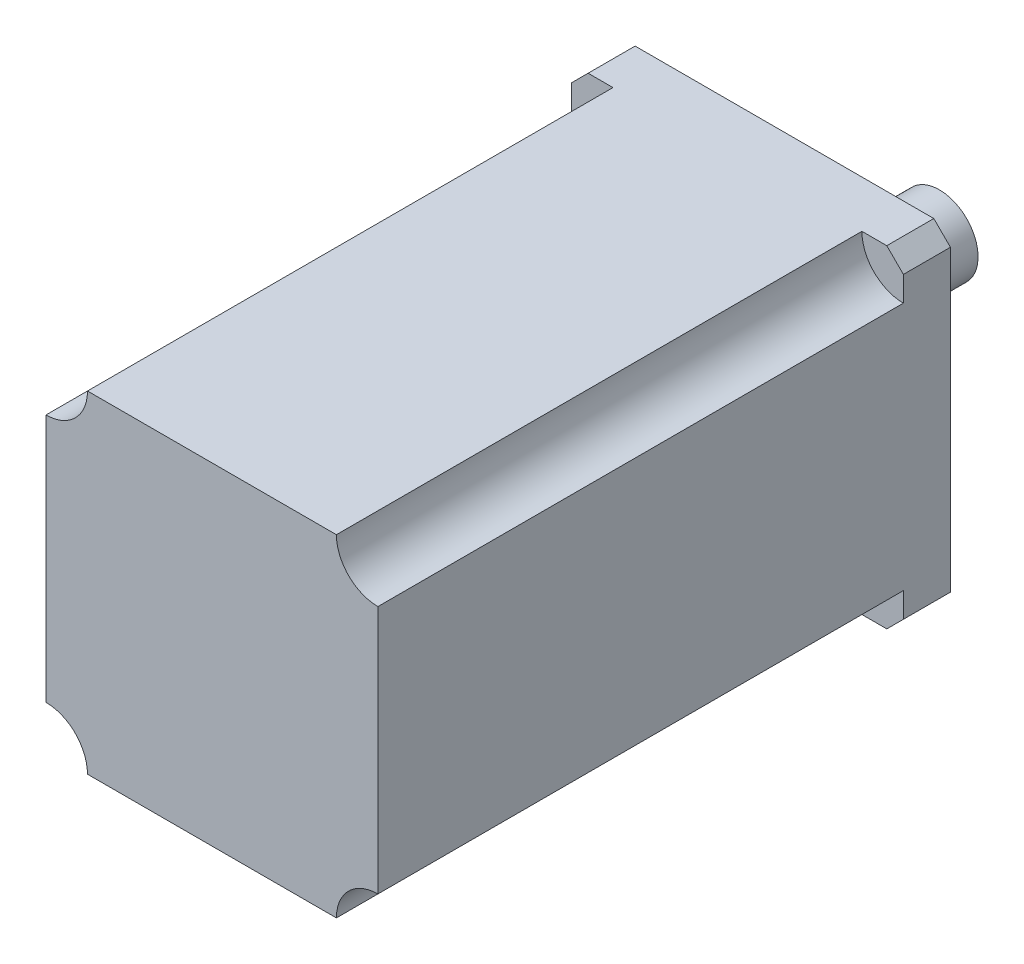
from build123d import *

# Parameters (mm, degrees)
EXTRUDE_1_DEPTH = 95
SKETCH_3_W      = 60
SKETCH_3_H      = 60
EXTRUDE_3_DEPTH = 8.5
SKETCH_5_R      = 25
EXTRUDE_5_DEPTH = 3
SKETCH_7_R      = 7
EXTRUDE_6_DEPTH = 25
CHAMFER_1_SIZE  = 3


with BuildPart() as part:
    # 草图1 → 凸台-拉伸1 (new body)
    with BuildSketch(Plane.XY):
        with BuildLine():
            Line((7.5, 0), (52.5, 0))
            ThreePointArc((52.5, 0), (54.696699141, -5.303300859), (60, -7.5))
            Line((60, -7.5), (60, -52.5))
            ThreePointArc((60, -52.5), (54.696699141, -54.696699141), (52.5, -60))
            Line((52.5, -60), (7.5, -60))
            ThreePointArc((7.5, -60), (5.303300859, -54.696699141), (0, -52.5))
            Line((0, -52.5), (0, -7.5))
            ThreePointArc((0, -7.5), (5.303300859, -5.303300859), (7.5, 0))
        make_face()
    extrude(amount=EXTRUDE_1_DEPTH)

    # 草图3 → 凸台-拉伸3 (add)
    with BuildSketch(Plane(origin=(0, 0, 0), x_dir=(-1, 0, 0), z_dir=(0, 0, -1))):
        with Locations((-30, -30)):
            Rectangle(SKETCH_3_W, SKETCH_3_H)
    extrude(amount=EXTRUDE_3_DEPTH)

    # 草图5 → 凸台-拉伸5 (add)
    with BuildSketch(Plane(origin=(0, 0, -8.5), x_dir=(-1, 0, 0), z_dir=(0, 0, -1))):
        with Locations((-30, -30)):
            Circle(SKETCH_5_R)
    extrude(amount=EXTRUDE_5_DEPTH)

    # 草图7 → 凸台-拉伸6 (add)
    with BuildSketch(Plane(origin=(0, 0, -11.5), x_dir=(-1, 0, 0), z_dir=(0, 0, -1))):
        with Locations((-30, -30)):
            Circle(SKETCH_7_R)
    extrude(amount=EXTRUDE_6_DEPTH)

    # 倒角1
    chamfer_1_edges = [part.edges().sort_by_distance(p)[0] for p in [
        (0, -60, -4.25),
        (0, 0, -4.25),
        (60, 0, -4.25),
        (60, -60, -4.25),
    ]]
    chamfer(chamfer_1_edges, length=CHAMFER_1_SIZE)


solid = part.part
